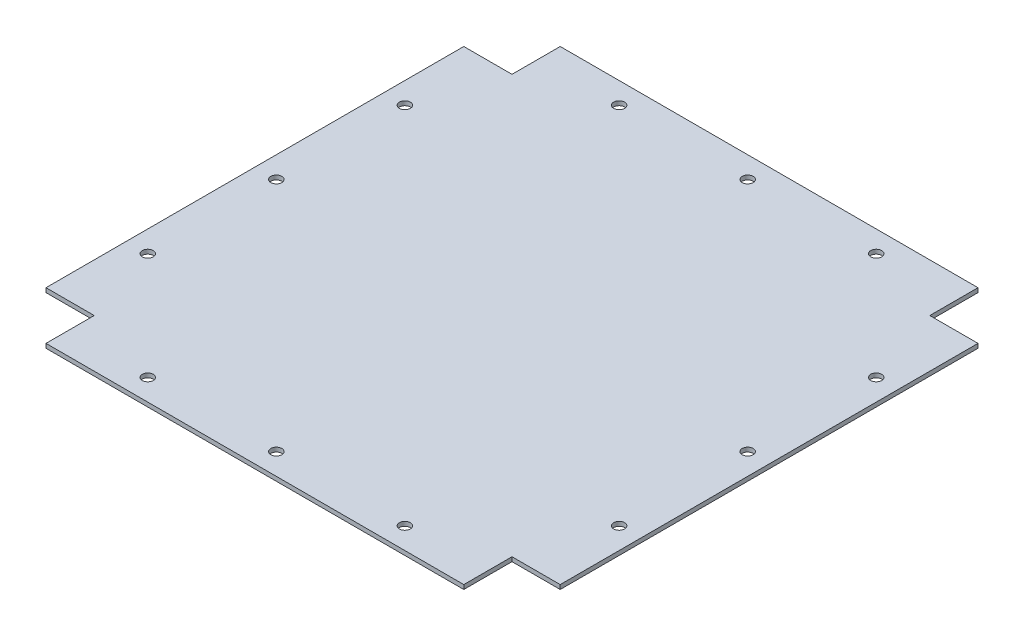
from build123d import *

# Parameters (mm, degrees)
SKETCH1_R           = 3.2385
BOSS_EXTRUDE1_DEPTH = 2.54


with BuildPart() as part:
    # Sketch1 → Boss-Extrude1 (new body)
    with BuildSketch(Plane(origin=(0, 0, 0), x_dir=(1, 0, 0), z_dir=(0, 1, 0))):
        Polygon((123.825, 152.4), (123.825, 123.825), (152.4, 123.825), (152.4, -123.825), (123.825, -123.825), (123.825, -152.4), (-123.825, -152.4), (-123.825, -123.825), (-152.4, -123.825), (-152.4, 123.825), (-123.825, 123.825), (-123.825, 152.4), align=None)
        with Locations((76.2, 139.7)):
            Circle(SKETCH1_R, mode=Mode.SUBTRACT)
        with Locations((0, 139.7)):
            Circle(SKETCH1_R, mode=Mode.SUBTRACT)
        with Locations((-76.2, 139.7)):
            Circle(SKETCH1_R, mode=Mode.SUBTRACT)
        with Locations((-76.2, -139.7)):
            Circle(SKETCH1_R, mode=Mode.SUBTRACT)
        with Locations((0, -139.7)):
            Circle(SKETCH1_R, mode=Mode.SUBTRACT)
        with Locations((76.2, -139.7)):
            Circle(SKETCH1_R, mode=Mode.SUBTRACT)
        with Locations((139.7, -76.2)):
            Circle(SKETCH1_R, mode=Mode.SUBTRACT)
        with Locations((139.7, 0)):
            Circle(SKETCH1_R, mode=Mode.SUBTRACT)
        with Locations((139.7, 76.2)):
            Circle(SKETCH1_R, mode=Mode.SUBTRACT)
        with Locations((-139.7, 76.2)):
            Circle(SKETCH1_R, mode=Mode.SUBTRACT)
        with Locations((-139.7, 0)):
            Circle(SKETCH1_R, mode=Mode.SUBTRACT)
        with Locations((-139.7, -76.2)):
            Circle(SKETCH1_R, mode=Mode.SUBTRACT)
    extrude(amount=BOSS_EXTRUDE1_DEPTH)


solid = part.part
